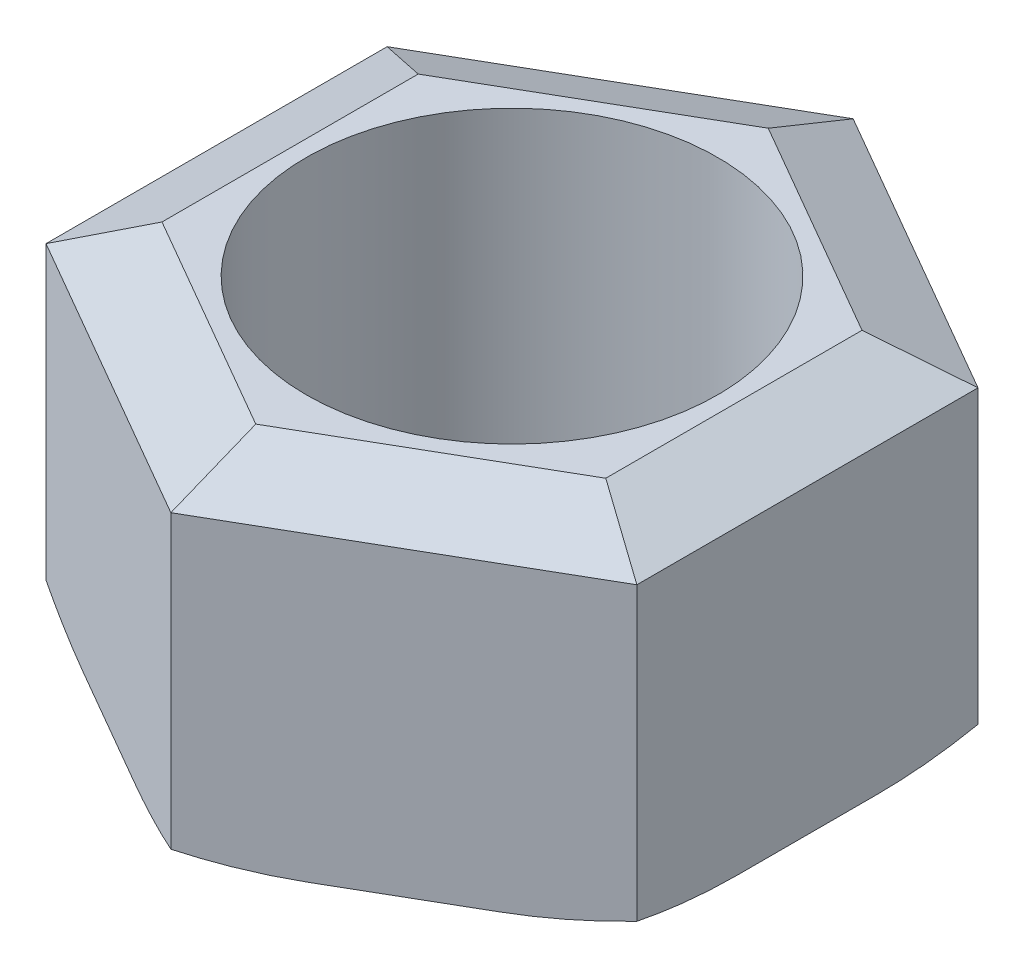
from build123d import *

# Parameters (mm, degrees)
SKETCH_1_R             = 6
EXTRUDE_1_DEPTH        = 10.8
CHAMFER_1_SIZE         = 1
CHAMFER_1_SIZE2        = 2.144506921
CHAMFER_1_PART_2_SIZE  = 1
CHAMFER_1_PART_2_SIZE2 = 2.144506921
CHAMFER_1_PART_3_SIZE  = 1
CHAMFER_1_PART_3_SIZE2 = 2.144506921
CHAMFER_1_PART_4_SIZE  = 1
CHAMFER_1_PART_4_SIZE2 = 2.144506921
CHAMFER_1_PART_5_SIZE  = 1
CHAMFER_1_PART_5_SIZE2 = 2.144506921
CHAMFER_1_PART_6_SIZE  = 1
CHAMFER_1_PART_6_SIZE2 = 2.144506921
CHAMFER_2_SIZE         = 1
CHAMFER_2_SIZE2        = 2.144506921
CHAMFER_2_PART_2_SIZE  = 1
CHAMFER_2_PART_2_SIZE2 = 2.144506921
CHAMFER_2_PART_3_SIZE  = 1
CHAMFER_2_PART_3_SIZE2 = 2.144506921
CHAMFER_2_PART_4_SIZE  = 1
CHAMFER_2_PART_4_SIZE2 = 2.144506921
CHAMFER_2_PART_5_SIZE  = 1
CHAMFER_2_PART_5_SIZE2 = 2.144506921
CHAMFER_2_PART_6_SIZE  = 1
CHAMFER_2_PART_6_SIZE2 = 2.144506921
FILLET_2_R             = 12


with BuildPart() as part:
    # Эскиз1 → Бобышка-Вытянуть1 (new body)
    with BuildSketch(Plane(origin=(0, 0, 0), x_dir=(1, 0, 0), z_dir=(0, 1, 0))):
        Polygon((0, 9.95), (-8.616952768, 4.975), (-8.616952768, -4.975), (0, -9.95), (8.616952768, -4.975), (8.616952768, 4.975), align=None)
        Circle(SKETCH_1_R, mode=Mode.SUBTRACT)
    extrude(amount=EXTRUDE_1_DEPTH)

    # Фаска1
    chamfer_1_edges = [part.edges().sort_by_distance(p)[0] for p in [
        (-8.616952768, 10.8, 0),
    ]]
    chamfer_1_side = [part.faces().sort_by_distance(p)[0] for p in [
        (-8.616952768, 5.4, 0),
    ]]
    chamfer(chamfer_1_edges, length=CHAMFER_1_SIZE, length2=CHAMFER_1_SIZE2, reference=chamfer_1_side[0])

    # Фаска1 part 2
    chamfer_1_part_2_edges = [part.edges().sort_by_distance(p)[0] for p in [
        (-4.308476384, 10.8, 7.4625),
    ]]
    chamfer_1_part_2_side = [part.faces().sort_by_distance(p)[0] for p in [
        (-4.308476384, 5.4, 7.4625),
    ]]
    chamfer(chamfer_1_part_2_edges, length=CHAMFER_1_PART_2_SIZE, length2=CHAMFER_1_PART_2_SIZE2, reference=chamfer_1_part_2_side[0])

    # Фаска1 part 3
    chamfer_1_part_3_edges = [part.edges().sort_by_distance(p)[0] for p in [
        (4.308476384, 10.8, 7.4625),
    ]]
    chamfer_1_part_3_side = [part.faces().sort_by_distance(p)[0] for p in [
        (4.308476384, 5.4, 7.4625),
    ]]
    chamfer(chamfer_1_part_3_edges, length=CHAMFER_1_PART_3_SIZE, length2=CHAMFER_1_PART_3_SIZE2, reference=chamfer_1_part_3_side[0])

    # Фаска1 part 4
    chamfer_1_part_4_edges = [part.edges().sort_by_distance(p)[0] for p in [
        (8.616952768, 10.8, 0),
    ]]
    chamfer_1_part_4_side = [part.faces().sort_by_distance(p)[0] for p in [
        (8.616952768, 5.4, 0),
    ]]
    chamfer(chamfer_1_part_4_edges, length=CHAMFER_1_PART_4_SIZE, length2=CHAMFER_1_PART_4_SIZE2, reference=chamfer_1_part_4_side[0])

    # Фаска1 part 5
    chamfer_1_part_5_edges = [part.edges().sort_by_distance(p)[0] for p in [
        (4.308476384, 10.8, -7.4625),
    ]]
    chamfer_1_part_5_side = [part.faces().sort_by_distance(p)[0] for p in [
        (4.308476384, 5.4, -7.4625),
    ]]
    chamfer(chamfer_1_part_5_edges, length=CHAMFER_1_PART_5_SIZE, length2=CHAMFER_1_PART_5_SIZE2, reference=chamfer_1_part_5_side[0])

    # Фаска1 part 6
    chamfer_1_part_6_edges = [part.edges().sort_by_distance(p)[0] for p in [
        (-4.308476384, 10.8, -7.4625),
    ]]
    chamfer_1_part_6_side = [part.faces().sort_by_distance(p)[0] for p in [
        (-4.308476384, 5.4, -7.4625),
    ]]
    chamfer(chamfer_1_part_6_edges, length=CHAMFER_1_PART_6_SIZE, length2=CHAMFER_1_PART_6_SIZE2, reference=chamfer_1_part_6_side[0])

    # Фаска2
    chamfer_2_edges = [part.edges().sort_by_distance(p)[0] for p in [
        (8.616952768, 0, 0),
    ]]
    chamfer_2_side = [part.faces().sort_by_distance(p)[0] for p in [
        (8.616952768, 4.9, 0),
    ]]
    chamfer(chamfer_2_edges, length=CHAMFER_2_SIZE, length2=CHAMFER_2_SIZE2, reference=chamfer_2_side[0])

    # Фаска2 part 2
    chamfer_2_part_2_edges = [part.edges().sort_by_distance(p)[0] for p in [
        (4.308476384, 0, 7.4625),
    ]]
    chamfer_2_part_2_side = [part.faces().sort_by_distance(p)[0] for p in [
        (4.308476384, 4.9, 7.4625),
    ]]
    chamfer(chamfer_2_part_2_edges, length=CHAMFER_2_PART_2_SIZE, length2=CHAMFER_2_PART_2_SIZE2, reference=chamfer_2_part_2_side[0])

    # Фаска2 part 3
    chamfer_2_part_3_edges = [part.edges().sort_by_distance(p)[0] for p in [
        (-4.308476384, 0, 7.4625),
    ]]
    chamfer_2_part_3_side = [part.faces().sort_by_distance(p)[0] for p in [
        (-4.308476384, 4.9, 7.4625),
    ]]
    chamfer(chamfer_2_part_3_edges, length=CHAMFER_2_PART_3_SIZE, length2=CHAMFER_2_PART_3_SIZE2, reference=chamfer_2_part_3_side[0])

    # Фаска2 part 4
    chamfer_2_part_4_edges = [part.edges().sort_by_distance(p)[0] for p in [
        (-8.616952768, 0, 0),
    ]]
    chamfer_2_part_4_side = [part.faces().sort_by_distance(p)[0] for p in [
        (-8.616952768, 4.9, 0),
    ]]
    chamfer(chamfer_2_part_4_edges, length=CHAMFER_2_PART_4_SIZE, length2=CHAMFER_2_PART_4_SIZE2, reference=chamfer_2_part_4_side[0])

    # Фаска2 part 5
    chamfer_2_part_5_edges = [part.edges().sort_by_distance(p)[0] for p in [
        (-4.308476384, 0, -7.4625),
    ]]
    chamfer_2_part_5_side = [part.faces().sort_by_distance(p)[0] for p in [
        (-4.308476384, 4.9, -7.4625),
    ]]
    chamfer(chamfer_2_part_5_edges, length=CHAMFER_2_PART_5_SIZE, length2=CHAMFER_2_PART_5_SIZE2, reference=chamfer_2_part_5_side[0])

    # Фаска2 part 6
    chamfer_2_part_6_edges = [part.edges().sort_by_distance(p)[0] for p in [
        (4.308476384, 0, -7.4625),
    ]]
    chamfer_2_part_6_side = [part.faces().sort_by_distance(p)[0] for p in [
        (4.308476384, 4.9, -7.4625),
    ]]
    chamfer(chamfer_2_part_6_edges, length=CHAMFER_2_PART_6_SIZE, length2=CHAMFER_2_PART_6_SIZE2, reference=chamfer_2_part_6_side[0])

    # Скругление2
    fillet_2_edges = [part.edges().sort_by_distance(p)[0] for p in [
        (7.544699307, 0.5, 4.355934176),
        (0, 0.5, 8.711868352),
        (7.544699307, 0.5, -4.355934176),
        (-7.544699307, 0.5, 4.355934176),
        (0, 0.5, -8.711868352),
        (-7.544699307, 0.5, -4.355934176),
    ]]
    fillet(fillet_2_edges, radius=FILLET_2_R)


solid = part.part
